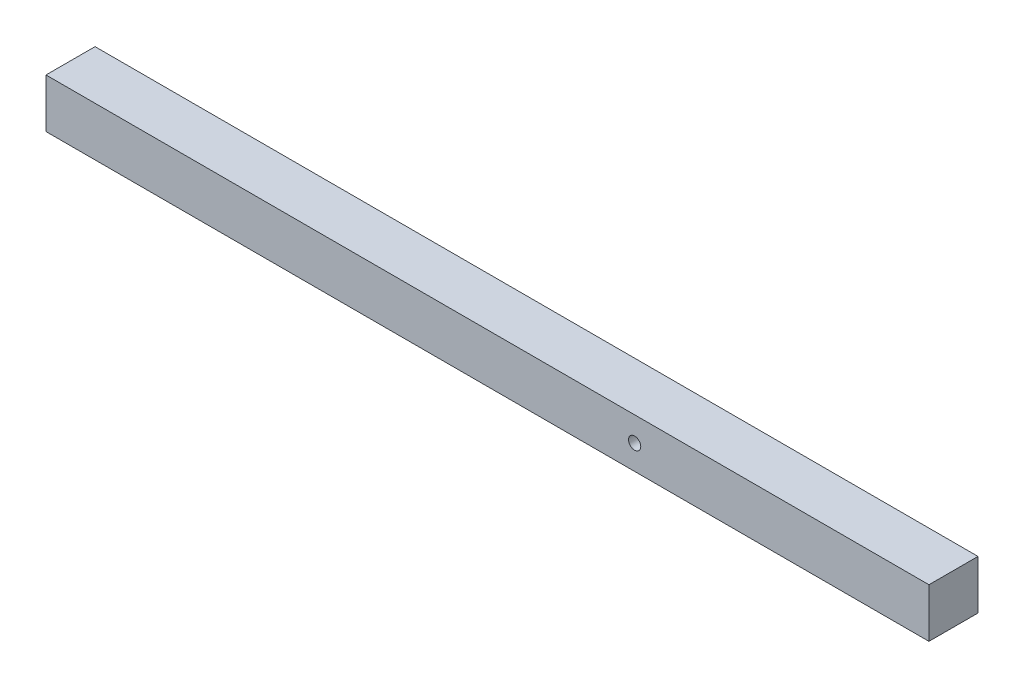
from build123d import *

# Parameters (mm, degrees)
SKETCH1_W               = 914.4
SKETCH1_H               = 50.8
BOSS_EXTRUDE1_DEPTH     = 50.8
SKETCH2_R               = 6.35
CUT_EXTRUDE1_DEPTH      = 26.4
CUT_EXTRUDE1_DEPTH_BACK = 26.4


with BuildPart() as part:
    # Sketch1 → Boss-Extrude1 (new body)
    with BuildSketch(Plane(origin=(0, 0, 0), x_dir=(1, 0, 0), z_dir=(0, 1, 0))):
        Rectangle(SKETCH1_W, SKETCH1_H)
    extrude(amount=BOSS_EXTRUDE1_DEPTH)

    # Sketch2 → Cut-Extrude1 (cut, two sides)
    with BuildSketch(Plane.XY) as cut_extrude1_sk:
        with Locations((152.4, 25.4)):
            Circle(SKETCH2_R)
    extrude(amount=CUT_EXTRUDE1_DEPTH, mode=Mode.SUBTRACT)
    extrude(cut_extrude1_sk.sketch, amount=-CUT_EXTRUDE1_DEPTH_BACK, mode=Mode.SUBTRACT)


solid = part.part
